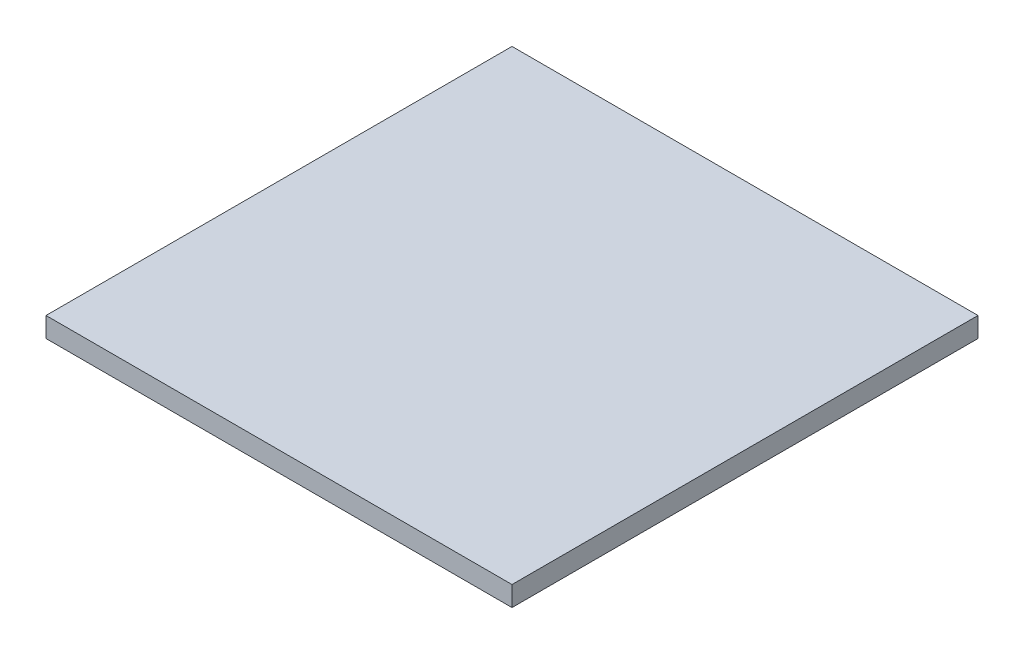
from build123d import *

# Parameters (mm, degrees)
SKETCH1_W    = 350
SKETCH1_H    = 350
BOTTOM_DEPTH = 15


with BuildPart() as part:
    # Sketch1 → bottom (new body)
    with BuildSketch(Plane(origin=(0, 0, 0), x_dir=(1, 0, 0), z_dir=(0, 1, 0))):
        with Locations((-283.461538462, 213.846153846)):
            Rectangle(SKETCH1_W, SKETCH1_H)
    extrude(amount=BOTTOM_DEPTH)


solid = part.part
